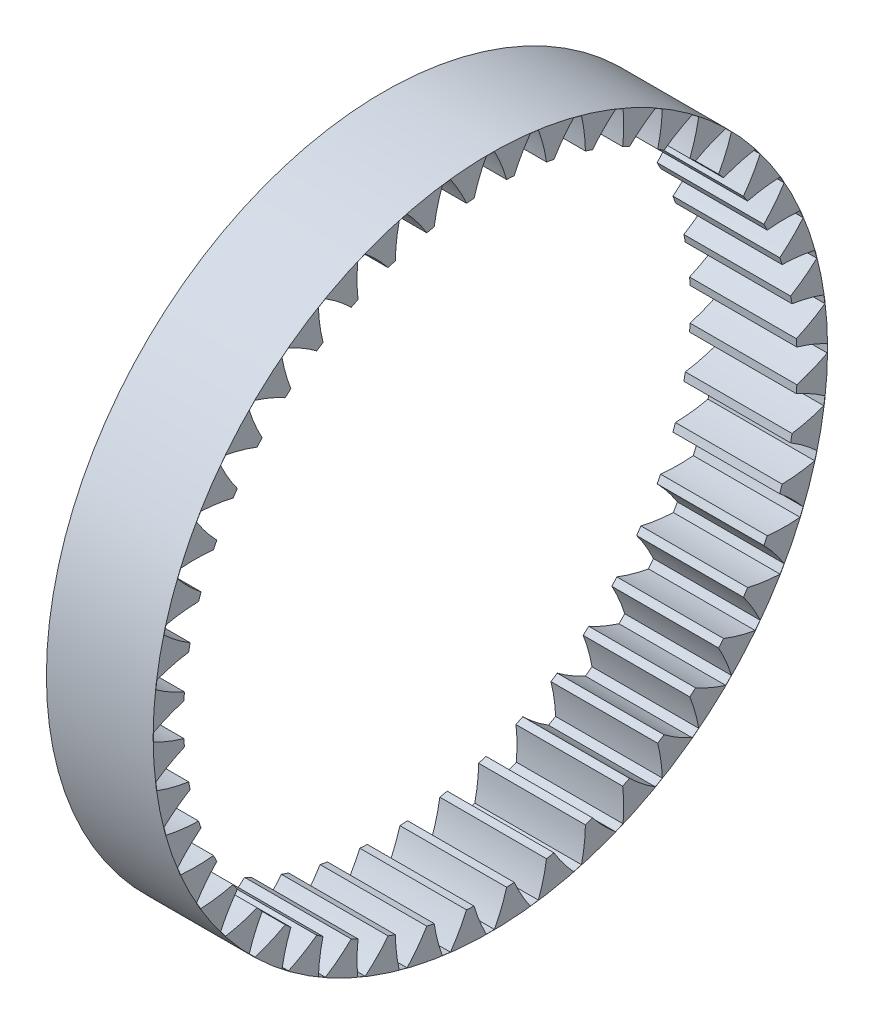
from build123d import *

# Parameters (mm, degrees)
BASPROSKE_W     = 8
BASPROSKE_H     = 2.2764
TOOTHCUT_DEPTH  = 37.630489949
TEETHCUTS_COUNT = 48
TEETHCUTS_ANGLE = 352.5


with BuildPart() as part:
    # BasProSke → Base-Revolve (revolve)
    with BuildSketch(Plane(origin=(0, 0, 0), x_dir=(1, 0, 0), z_dir=(0, 1, 0))):
        with Locations((4, 24.1382)):
            Rectangle(BASPROSKE_W, BASPROSKE_H)
    revolve(axis=Axis((-10, 0, 0), (1, 0, 0)))

    # TooCutSke → ToothCut (cut, through all)
    with BuildSketch(Plane(origin=(0, 0, 0), x_dir=(0, 0, -1), z_dir=(1, 0, 0))):
        with BuildLine():
            ThreePointArc((1.228366948, 22.941738378), (0.827025782, 24.119384933), (0.305907813, 25.249146944))
            ThreePointArc((0.305907813, 25.249146944), (0, 25.251), (-0.305907813, 25.249146944))
            ThreePointArc((-0.305907813, 25.249146944), (-0.827025782, 24.119384933), (-1.228366948, 22.941738378))
            ThreePointArc((-1.228366948, 22.941738378), (0, 22.9746), (1.228366948, 22.941738378))
        make_face()
    toothcut = extrude(amount=TOOTHCUT_DEPTH, mode=Mode.SUBTRACT)

    # TeethCuts: ToothCut ×48 about axis
    teethcuts_axis = Axis((-10, 0, 0), (1, 0, 0))
    for i in range(1, TEETHCUTS_COUNT):
        add(toothcut.rotate(teethcuts_axis, i * TEETHCUTS_ANGLE / (TEETHCUTS_COUNT - 1)), mode=Mode.SUBTRACT)


solid = part.part
